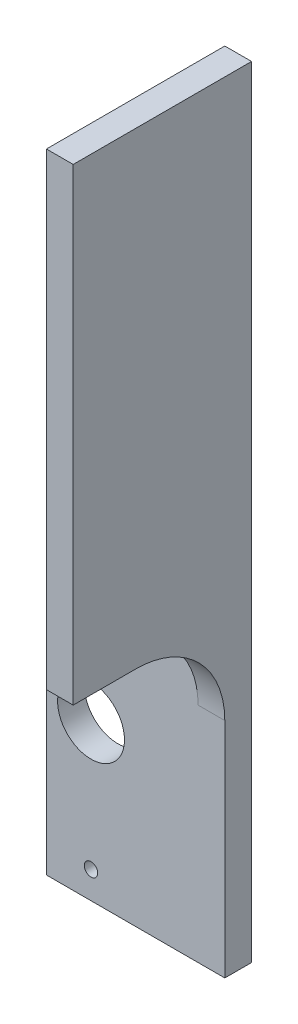
from build123d import *

# Parameters (mm, degrees)
SKETCH1_R           = 0.75
SKETCH1_R_2         = 3.75
BOSS_EXTRUDE1_DEPTH = 3
SKETCH2_W           = 3
SKETCH2_H           = 20
BOSS_EXTRUDE2_DEPTH = 52.5
FILLET5_R           = 10


with BuildPart() as part:
    # Sketch1 → Boss-Extrude1 (new body)
    with BuildSketch(Plane.XY):
        Polygon((0, 0), (-10, 0), (-10, 35), (0, 35), (10, 35), (10, 0), align=None)
        with Locations((-5, 31.95)):
            Circle(SKETCH1_R, mode=Mode.SUBTRACT)
        with Locations((-5, 3.05)):
            Circle(SKETCH1_R, mode=Mode.SUBTRACT)
        with Locations((-5, 17.5)):
            Circle(SKETCH1_R_2, mode=Mode.SUBTRACT)
    extrude(amount=BOSS_EXTRUDE1_DEPTH)

    # Sketch2 → Boss-Extrude2 (add)
    with BuildSketch(Plane(origin=(0, 35, 0), x_dir=(1, 0, 0), z_dir=(0, 1, 0))):
        with Locations((8.5, -10)):
            Rectangle(SKETCH2_W, SKETCH2_H)
    extrude(amount=BOSS_EXTRUDE2_DEPTH)

    # Fillet5
    fillet5_edges = [part.edges().sort_by_distance(p)[0] for p in [
        (8.5, 35, 3),
    ]]
    fillet(fillet5_edges, radius=FILLET5_R)


solid = part.part
